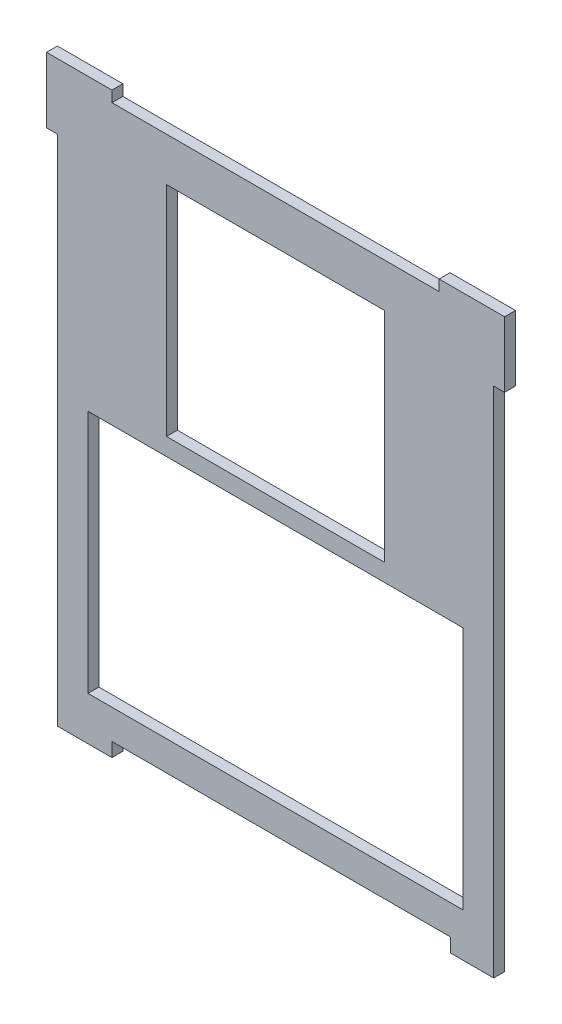
from build123d import *

# Parameters (mm, degrees)
SKETCH1_W           = 127
SKETCH1_H           = 177.8
BOSS_EXTRUDE1_DEPTH = 3.175
SKETCH3_W           = 63.5
SKETCH3_H           = 63.5
SKETCH3_W_2         = 109.22
SKETCH3_H_2         = 71.12
CUT_EXTRUDE2_DEPTH  = 4.175
BOSS_EXTRUDE2_DEPTH = 3.175
CUT_EXTRUDE3_REACH  = 5.175
SKETCH5_W           = 19.05
SKETCH5_H           = 12.7
SKETCH6_W           = 3.302
SKETCH6_H           = 12.7
CUT_EXTRUDE4_DEPTH  = 4.175
CUT_EXTRUDE5_DEPTH  = 4.175
SKETCH9_W           = 6.477
SKETCH9_H           = 4.064
CUT_EXTRUDE6_DEPTH  = 4.175


with BuildPart() as part:
    # Sketch1 → Boss-Extrude1 (new body)
    with BuildSketch(Plane.XY):
        Rectangle(SKETCH1_W, SKETCH1_H)
    extrude(amount=BOSS_EXTRUDE1_DEPTH)

    # Sketch3 → Cut-Extrude2 (cut, through all)
    with BuildSketch(Plane.XY.offset(3.175)):
        with Locations((0, 44.45)):
            Rectangle(SKETCH3_W, SKETCH3_H)
        with Locations((0, -27.94)):
            Rectangle(SKETCH3_W_2, SKETCH3_H_2)
    extrude(amount=-CUT_EXTRUDE2_DEPTH, mode=Mode.SUBTRACT)

    # Sketch4 → Boss-Extrude2 (add)
    with BuildSketch(Plane.XY.offset(3.175)):
        Polygon((-60.325, 92.075), (-66.675, 92.075), (-66.675, 85.725), (-66.675, 73.025), (-60.325, 73.025), (-60.325, 85.725), (-47.625, 85.725), (-47.625, 92.075), align=None)
        Polygon((60.325, 92.075), (66.675, 92.075), (66.675, 85.725), (66.675, 73.025), (60.325, 73.025), (60.325, 85.725), (47.625, 85.725), (47.625, 92.075), align=None)
    extrude(amount=-BOSS_EXTRUDE2_DEPTH)

    # Sketch5 → Cut-Extrude3 (cut, up to next)
    with BuildSketch(Plane.XY.offset(3.175), mode=Mode.PRIVATE) as cut_extrude3_sk1:
        with Locations((-53.975, -82.55)):
            Rectangle(SKETCH5_W, SKETCH5_H)
    cut_extrude3_tool1 = extrude(cut_extrude3_sk1.sketch, amount=-CUT_EXTRUDE3_REACH, mode=Mode.PRIVATE) & part.part
    add(cut_extrude3_tool1.solids().sort_by_distance((-53.975, -82.55, 3.175))[0], mode=Mode.SUBTRACT)
    # Sketch5 → Cut-Extrude3 (cut, up to next)
    with BuildSketch(Plane.XY.offset(3.175), mode=Mode.PRIVATE) as cut_extrude3_sk2:
        with Locations((53.975, -82.55)):
            Rectangle(SKETCH5_W, SKETCH5_H)
    cut_extrude3_tool2 = extrude(cut_extrude3_sk2.sketch, amount=-CUT_EXTRUDE3_REACH, mode=Mode.PRIVATE) & part.part
    add(cut_extrude3_tool2.solids().sort_by_distance((53.975, -82.55, 3.175))[0], mode=Mode.SUBTRACT)

    # Sketch6 → Cut-Extrude4 (cut, through all)
    with BuildSketch(Plane.XY.offset(3.175)):
        with Locations((-42.799, -82.55)):
            Rectangle(SKETCH6_W, SKETCH6_H)
    extrude(amount=-CUT_EXTRUDE4_DEPTH, mode=Mode.SUBTRACT)

    # Sketch7 → Cut-Extrude5 (cut, through all)
    with BuildSketch(Plane.XY.offset(3.175)):
        Polygon((-41.148, -76.2), (-41.148, -72.136), (44.45, -72.136), (44.45, -76.2), (44.45, -88.9), (-41.148, -88.9), align=None)
    extrude(amount=-CUT_EXTRUDE5_DEPTH, mode=Mode.SUBTRACT)

    # Sketch9 → Cut-Extrude6 (cut, through all)
    with BuildSketch(Plane.XY.offset(3.175)):
        with Locations((-44.3865, -74.168)):
            Rectangle(SKETCH9_W, SKETCH9_H)
        with Locations((47.6885, -74.168)):
            Rectangle(SKETCH9_W, SKETCH9_H)
    extrude(amount=-CUT_EXTRUDE6_DEPTH, mode=Mode.SUBTRACT)


solid = part.part
